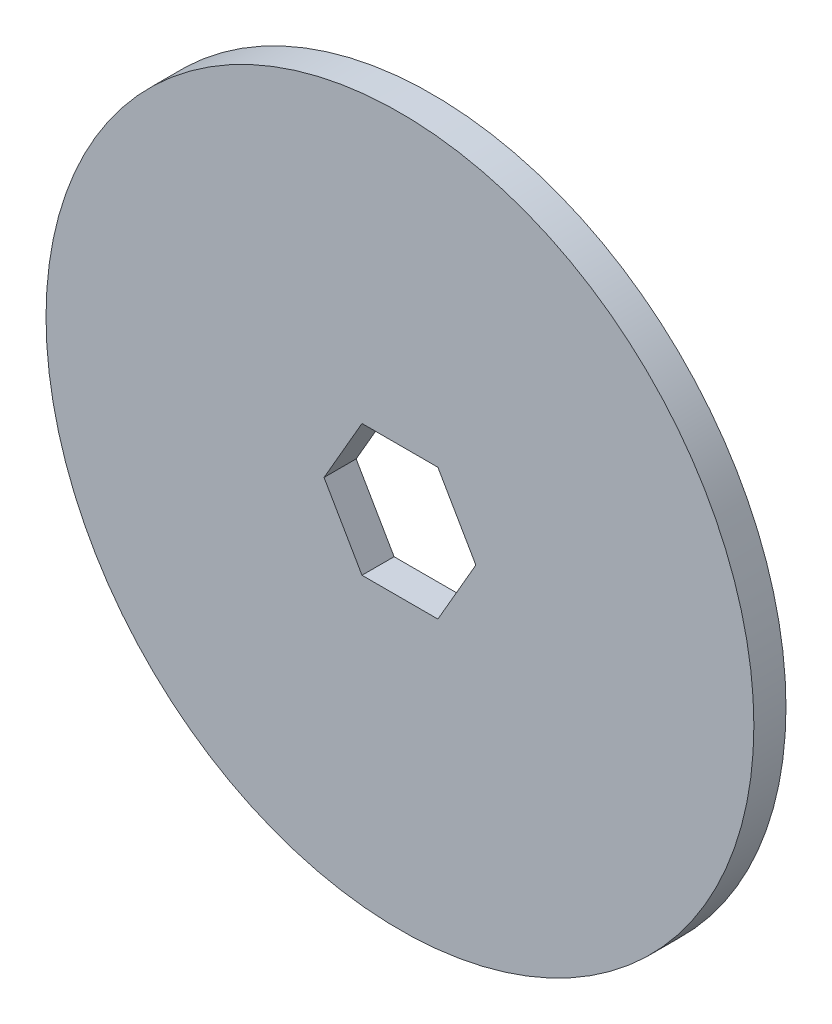
from build123d import *

# Parameters (mm, degrees)
SKETCH1_R           = 35
BOSS_EXTRUDE1_DEPTH = 3.175
CUT_EXTRUDE1_REACH  = 5.175


with BuildPart() as part:
    # Sketch1 → Boss-Extrude1 (new body)
    with BuildSketch(Plane.XY):
        Circle(SKETCH1_R)
    extrude(amount=BOSS_EXTRUDE1_DEPTH)

    # Sketch2 → Cut-Extrude1 (cut, up to next)
    with BuildSketch(Plane.XY.offset(3.175), mode=Mode.PRIVATE) as cut_extrude1_sk1:
        Polygon((7.505553499, 0), (3.75277675, 6.5), (-3.75277675, 6.5), (-7.505553499, 0), (-3.75277675, -6.5), (3.75277675, -6.5), align=None)
    cut_extrude1_tool1 = extrude(cut_extrude1_sk1.sketch, amount=-CUT_EXTRUDE1_REACH, mode=Mode.PRIVATE) & part.part
    add(cut_extrude1_tool1.solids().sort_by_distance((0, 0, 3.175))[0], mode=Mode.SUBTRACT)


solid = part.part
